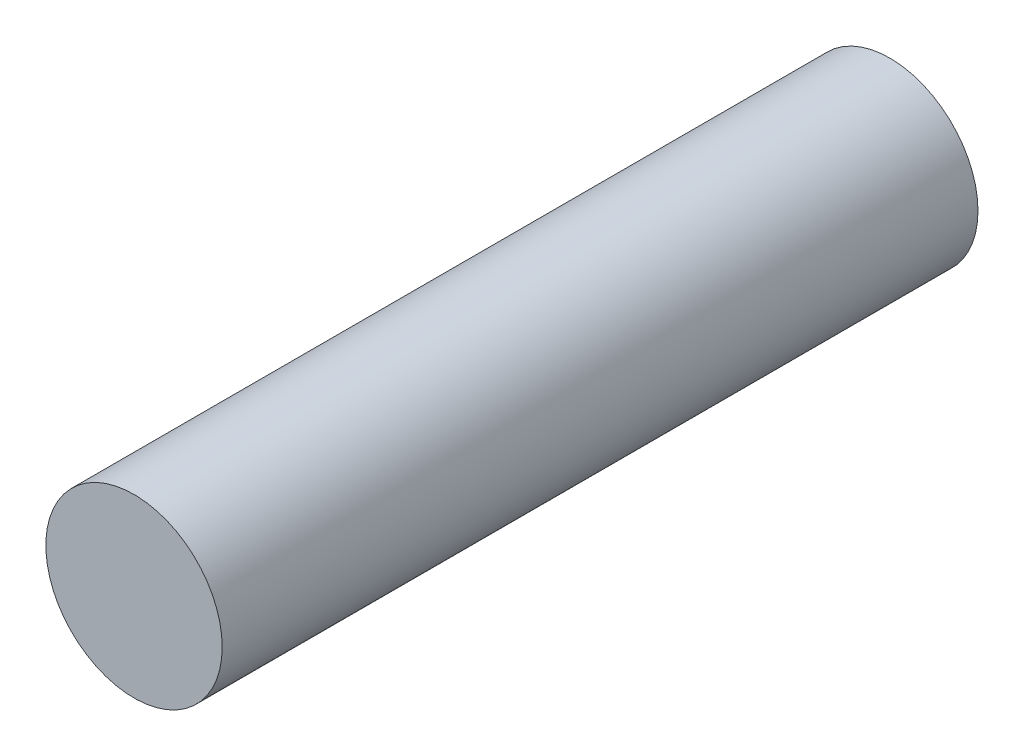
from build123d import *

# Parameters (mm, degrees)
SKETCH1_R           = 0.35
BOSS_EXTRUDE1_DEPTH = 3


with BuildPart() as part:
    # Sketch1 → Boss-Extrude1 (new body)
    with BuildSketch(Plane.XY):
        Circle(SKETCH1_R)
    extrude(amount=BOSS_EXTRUDE1_DEPTH)


solid = part.part
